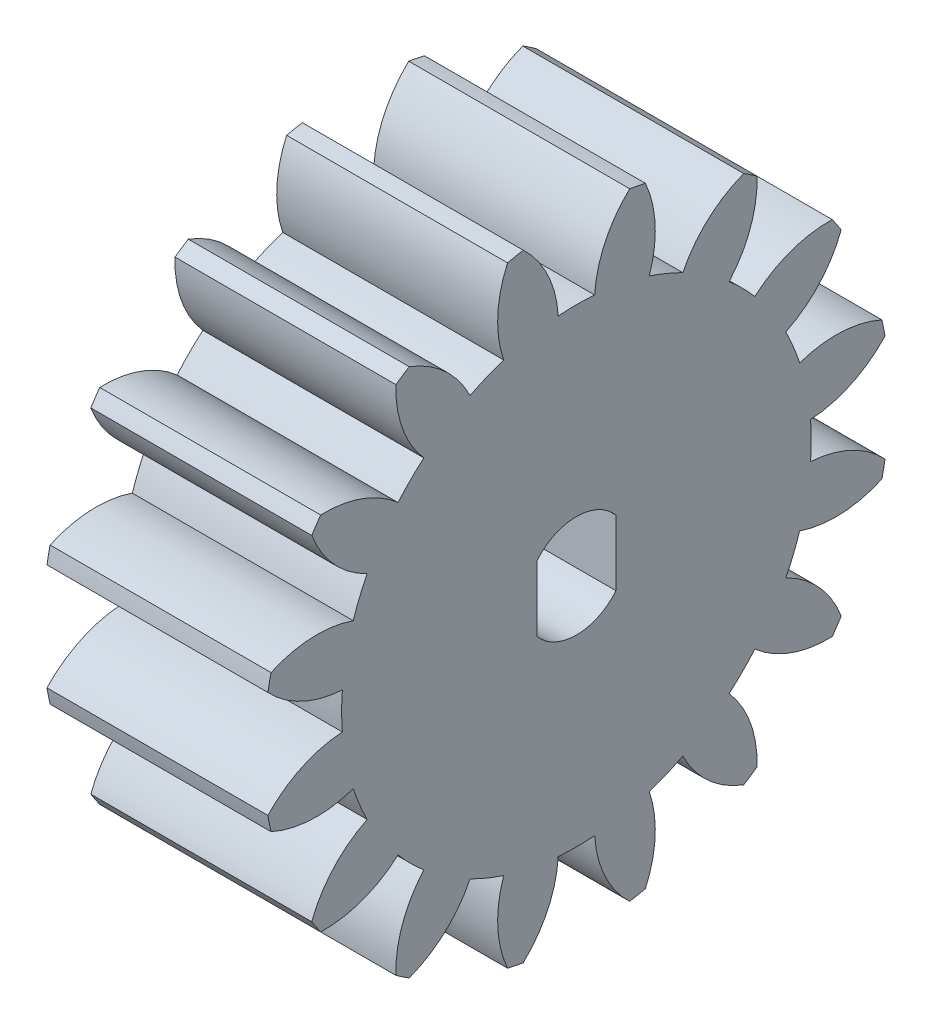
from build123d import *

# Parameters (mm, degrees)
BASPROSKE_W        = 6.35
BASPROSKE_H        = 9
TOOTHCUT_DEPTH     = 15.224011389
TEETHCUTS_COUNT    = 16
TEETHCUTS_ANGLE    = 337.5
BORSKE_R           = 0.5
BORE_DEPTH         = 50.00127
SKETCH1_R          = 0.5
CUT_EXTRUDE1_DEPTH = 10


with BuildPart() as part:
    # BasProSke → Base-Revolve (revolve)
    with BuildSketch(Plane(origin=(0, 0, 0), x_dir=(1, 0, 0), z_dir=(0, 1, 0)), mode=Mode.PRIVATE) as base_revolve_sk:
        with Locations((3.175, 4.5)):
            Rectangle(BASPROSKE_W, BASPROSKE_H)
    revolve(base_revolve_sk.sketch.rotate(Axis((-10, 0, 0), (1, 0, 0)), 180), axis=Axis((-10, 0, 0), (1, 0, 0)))

    # TooCutSke → ToothCut (cut, through all)
    with BuildSketch(Plane(origin=(0, 0, 0), x_dir=(0, 0, -1), z_dir=(1, 0, 0))):
        with BuildLine():
            ThreePointArc((0.523792937, 6.728643397), (0, 6.749), (-0.523792937, 6.728643397))
            ThreePointArc((-0.523792937, 6.728643397), (-0.828704482, 7.90962059), (-1.553355277, 8.890721711))
            ThreePointArc((-1.553355277, 8.890721711), (0, 9.0254), (1.553355277, 8.890721711))
            ThreePointArc((1.553355277, 8.890721711), (0.828704482, 7.90962059), (0.523792937, 6.728643397))
        make_face()
    toothcut = extrude(amount=TOOTHCUT_DEPTH, mode=Mode.SUBTRACT)

    # TeethCuts: ToothCut ×16 about axis
    teethcuts_axis = Axis((-10, 0, 0), (1, 0, 0))
    for i in range(1, TEETHCUTS_COUNT):
        add(toothcut.rotate(teethcuts_axis, i * TEETHCUTS_ANGLE / (TEETHCUTS_COUNT - 1)), mode=Mode.SUBTRACT)

    # BorSke → Bore (cut, symmetric)
    with BuildSketch(Plane(origin=(0, 0, 0), x_dir=(0, 0, -1), z_dir=(1, 0, 0))):
        with Locations(Location((0, 0, 0), (0, 0, 180))):
            Circle(BORSKE_R)
    extrude(amount=BORE_DEPTH, both=True, mode=Mode.SUBTRACT)

    # Sketch1 → Cut-Extrude1 (cut)
    with BuildSketch(Plane(origin=(6.35, 0, 0), x_dir=(0, 0, -1), z_dir=(1, 0, 0))):
        with BuildLine():
            ThreePointArc((1.136672776, 0.94), (0, 1.475), (-1.136672776, 0.94))
            Line((-1.136672776, 0.94), (-1.136672776, -0.94))
            ThreePointArc((-1.136672776, -0.94), (0, -1.475), (1.136672776, -0.94))
            Line((1.136672776, -0.94), (1.136672776, 0.94))
        make_face()
        Circle(SKETCH1_R, mode=Mode.SUBTRACT)
    extrude(amount=-CUT_EXTRUDE1_DEPTH, mode=Mode.SUBTRACT)


solid = part.part
